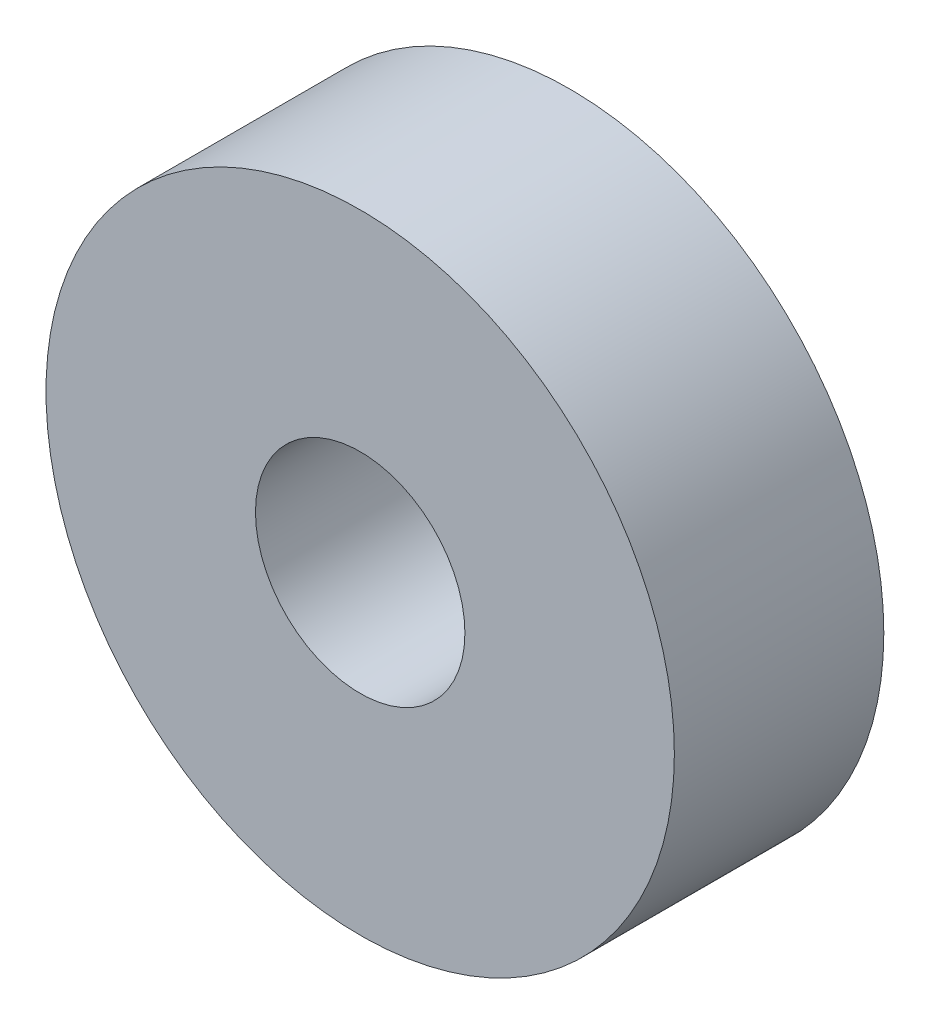
from build123d import *

# Parameters (mm, degrees)
SKETCH1_R           = 6
SKETCH1_R_2         = 2
BOSS_EXTRUDE1_DEPTH = 4


with BuildPart() as part:
    # Sketch1 → Boss-Extrude1 (new body)
    with BuildSketch(Plane.XY):
        Circle(SKETCH1_R)
        Circle(SKETCH1_R_2, mode=Mode.SUBTRACT)
    extrude(amount=BOSS_EXTRUDE1_DEPTH)


solid = part.part
